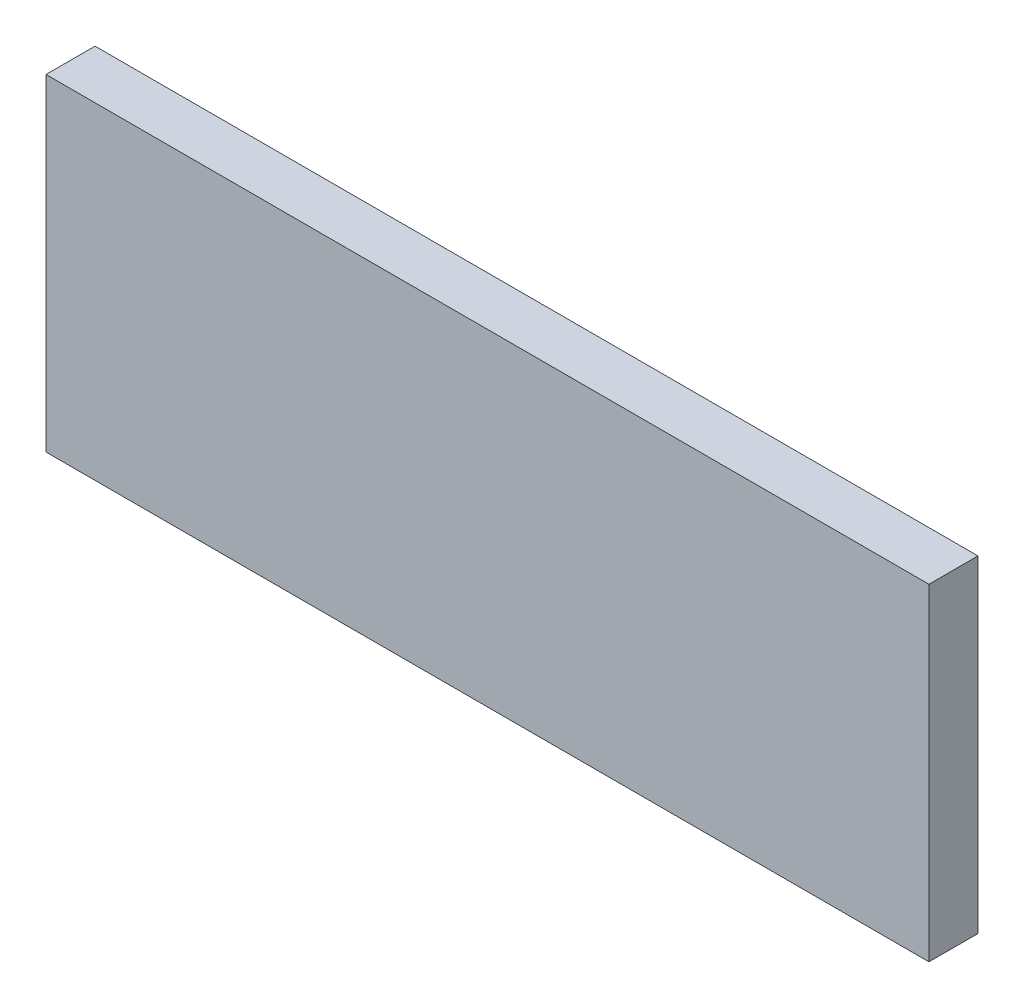
from build123d import *

# Parameters (mm, degrees)
SKETCH1_W           = 27
SKETCH1_H           = 10
BOSS_EXTRUDE1_DEPTH = 1.5


with BuildPart() as part:
    # Sketch1 → Boss-Extrude1 (new body)
    with BuildSketch(Plane.XY):
        Rectangle(SKETCH1_W, SKETCH1_H)
    extrude(amount=BOSS_EXTRUDE1_DEPTH)


solid = part.part
